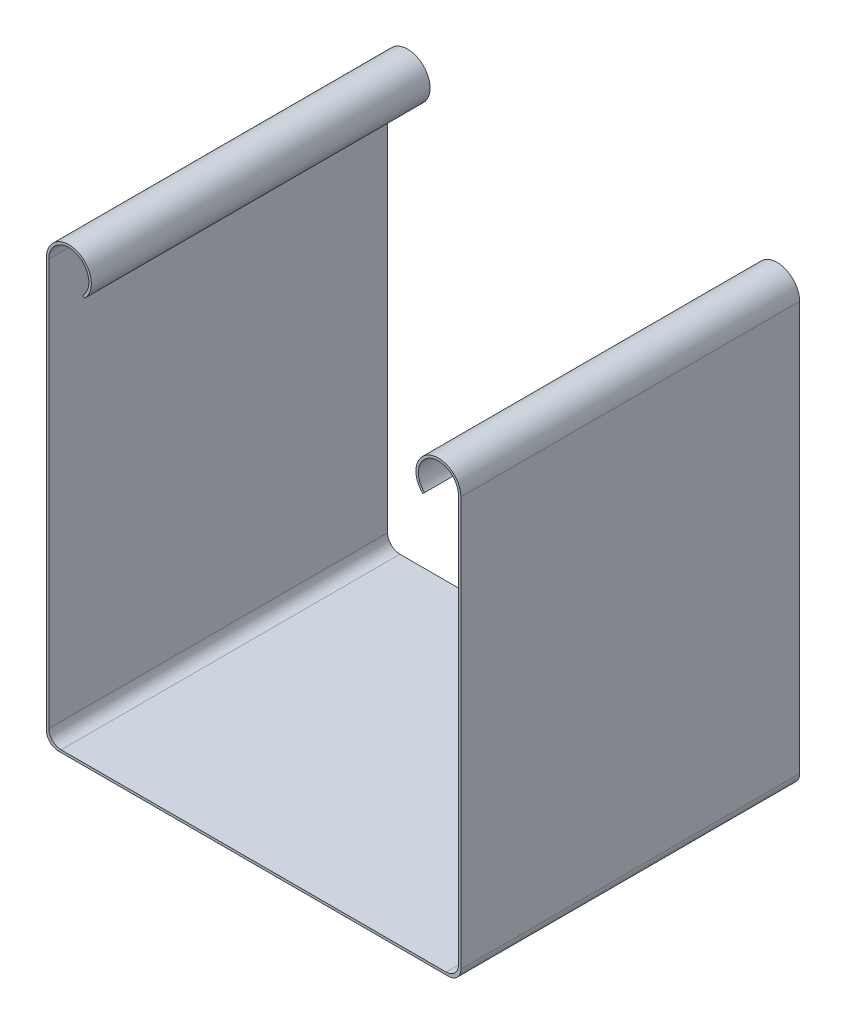
from build123d import *

# Parameters (mm, degrees)
BOSS_EXTRU_2_DEPTH = 55
CONG_2_R           = 2


with BuildPart() as part:
    # Esquisse1 → Boss.-Extru.2 (new body)
    with BuildSketch(Plane.XY):
        with BuildLine():
            Line((33.25, 68), (33.25, 34))
            Line((33.25, 34), (33.25, 0))
            Line((33.25, 0), (0, 0))
            Line((0, 0), (0, -0.4))
            Line((0, -0.4), (33.65, -0.4))
            Line((33.65, -0.4), (33.65, 34))
            Line((33.65, 34), (33.65, 68))
            ThreePointArc((33.65, 68), (28.572164781, 71.359134798), (27.46710324, 65.37189536))
            Line((27.46710324, 65.37189536), (27.75, 65.65479212))
            ThreePointArc((27.75, 65.65479212), (28.725245122, 70.989565186), (33.25, 68))
        make_face()
    extrude(amount=BOSS_EXTRU_2_DEPTH)

    # Congé2
    cong_2_edges = [part.edges().sort_by_distance(p)[0] for p in [
        (33.25, 0, 27.5),
        (33.65, -0.4, 27.5),
    ]]
    fillet(cong_2_edges, radius=CONG_2_R)

    # Symétrie2: part across plane


with BuildPart() as part_1:
    add(part.part)
    add(part.part.mirror(Plane(origin=(0, -0.4, 55), x_dir=(0, 0, 1), z_dir=(1, 0, 0))))


solid = part_1.part
